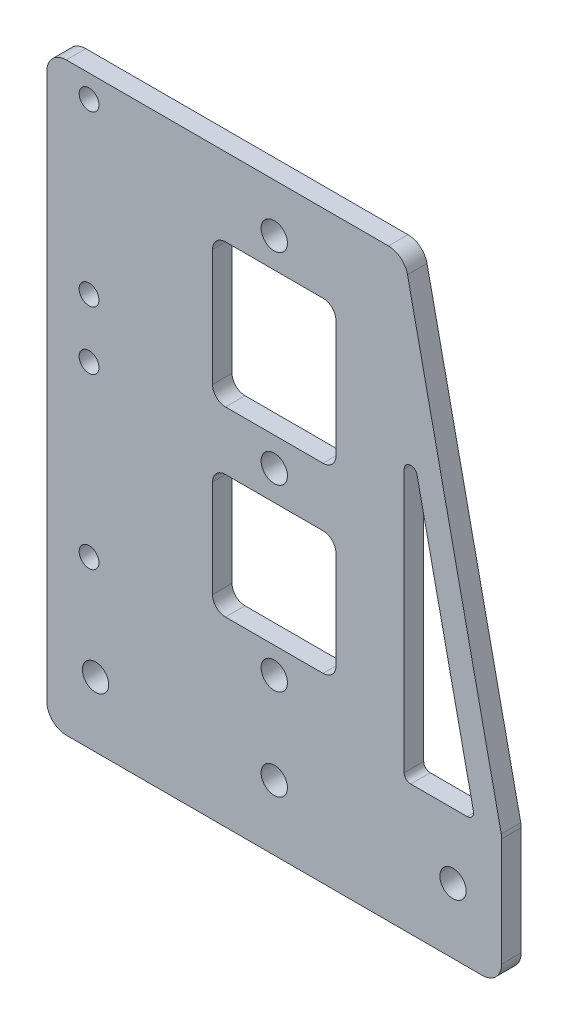
from build123d import *

# Parameters (mm, degrees)
EXTRUDE_1_DEPTH          = 3
SKETCH_3_W               = 19
SKETCH_3_H               = 22
SKETCH_3_H_2             = 19
CUT_EXTRUDE_1_DEPTH      = 3
FILLET_1_R               = 1
FILLET_2_R               = 2
SKETCH_4_R               = 2.025
CUT_EXTRUDE_2_DEPTH      = 3
SKETCH_5_R               = 2.025
CUT_EXTRUDE_3_DEPTH      = 10
EXTRUDE_2_DEPTH          = 3
FILLET_3_R               = 3
SKETCH_8_R               = 1.525
CUT_EXTRUDE_4_DEPTH      = 1
CUT_EXTRUDE_4_DEPTH_BACK = 4


with BuildPart() as part:
    # 草图1 → 凸台-拉伸1 (new body)
    with BuildSketch(Plane.XY):
        Polygon((0, 0), (-70, 0), (-70, 20), (-55, 90), (-15, 90), (0, 20), align=None)
    extrude(amount=EXTRUDE_1_DEPTH)

    # 草图3 → 切除-拉伸1 (cut)
    with BuildSketch(Plane.XY.offset(3)):
        with Locations((-35, 67)):
            Rectangle(SKETCH_3_W, SKETCH_3_H)
        with Locations((-35, 37.5)):
            Rectangle(SKETCH_3_W, SKETCH_3_H_2)
        Polygon((-4.090806018, 20), (-15, 70.909571916), (-15, 20), align=None)
    extrude(amount=-CUT_EXTRUDE_1_DEPTH, mode=Mode.SUBTRACT)

    # 圆角1
    fillet_1_edges = [part.edges().sort_by_distance(p)[0] for p in [
        (-4.090806018, 20, 1.5),
        (-15, 20, 1.5),
        (-15, 70.909571916, 1.5),
    ]]
    fillet(fillet_1_edges, radius=FILLET_1_R)

    # 圆角2
    fillet_2_edges = [part.edges().sort_by_distance(p)[0] for p in [
        (-25.5, 47, 1.5),
        (-25.5, 28, 1.5),
        (-44.5, 28, 1.5),
        (-44.5, 47, 1.5),
        (-25.5, 78, 1.5),
        (-25.5, 56, 1.5),
        (-44.5, 56, 1.5),
        (-44.5, 78, 1.5),
    ]]
    fillet(fillet_2_edges, radius=FILLET_2_R)

    # 草图4 → 切除-拉伸2 (cut)
    with BuildSketch(Plane.XY.offset(3)):
        with Locations((-62.5, 10)):
            Circle(SKETCH_4_R)
        with Locations((-35, 10)):
            Circle(SKETCH_4_R)
        with Locations((-7.5, 10)):
            Circle(SKETCH_4_R)
    extrude(amount=-CUT_EXTRUDE_2_DEPTH, mode=Mode.SUBTRACT)

    # 草图5 → 切除-拉伸3 (cut)
    with BuildSketch(Plane(origin=(0, 0, 0), x_dir=(-1, 0, 0), z_dir=(0, 0, -1))):
        with Locations((35, 82.566965626)):
            Circle(SKETCH_5_R)
        with Locations((35, 51.566965626)):
            Circle(SKETCH_5_R)
        with Locations((35, 24)):
            Circle(SKETCH_5_R)
    extrude(amount=-CUT_EXTRUDE_3_DEPTH, mode=Mode.SUBTRACT)

    # 草图7 → 凸台-拉伸2 (add)
    with BuildSketch(Plane.XY.offset(3)):
        Polygon((-55, 90), (-70, 90), (-70, 20), align=None)
    extrude(amount=-EXTRUDE_2_DEPTH)

    # 圆角3
    fillet_3_edges = [part.edges().sort_by_distance(p)[0] for p in [
        (0, 0, 1.5),
        (-70, 0, 1.5),
        (-15, 90, 1.5),
        (0, 20, 1.5),
        (-70, 90, 1.5),
    ]]
    fillet(fillet_3_edges, radius=FILLET_3_R)

    # 草图8 → 切除-拉伸4 (cut, two sides)
    with BuildSketch(Plane.XY.offset(3)) as cut_extrude_4_sk:
        with Locations((-63.5, 86.5)):
            Circle(SKETCH_8_R)
        with Locations((-63.5, 60.5)):
            Circle(SKETCH_8_R)
        with Locations((-63.5, 51.5)):
            Circle(SKETCH_8_R)
        with Locations((-63.5, 25.5)):
            Circle(SKETCH_8_R)
    extrude(amount=CUT_EXTRUDE_4_DEPTH, mode=Mode.SUBTRACT)
    extrude(cut_extrude_4_sk.sketch, amount=-CUT_EXTRUDE_4_DEPTH_BACK, mode=Mode.SUBTRACT)


solid = part.part
